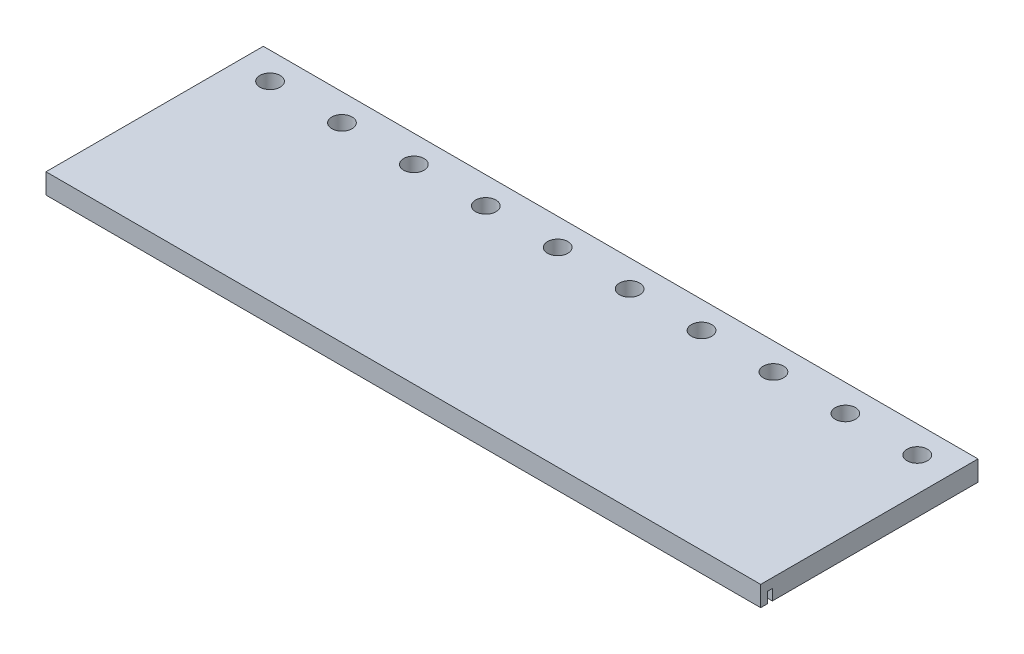
from build123d import *

# Parameters (mm, degrees)
SKETCH1_W               = 673.1
SKETCH1_H               = 204.6732
BOSS_EXTRUDE1_DEPTH     = 9.525
SKETCH2_R               = 9.584587104
CUT_EXTRUDE1_DEPTH      = 1
CUT_EXTRUDE1_DEPTH_BACK = 20.05
SKETCH4_W               = 673.1
SKETCH4_H               = 4.699
CUT_EXTRUDE2_DEPTH      = 10.16
CUT_EXTRUDE5_DEPTH      = 7.9375


with BuildPart() as part:
    # Sketch1 → Boss-Extrude1 (new body, symmetric)
    with BuildSketch(Plane(origin=(0, 0, 0), x_dir=(1, 0, 0), z_dir=(0, 1, 0))):
        Rectangle(SKETCH1_W, SKETCH1_H)
    extrude(amount=BOSS_EXTRUDE1_DEPTH, both=True)

    # Sketch2 → Cut-Extrude1 (cut, two sides)
    with BuildSketch(Plane(origin=(0, 9.525, 0), x_dir=(1, 0, 0), z_dir=(0, 1, 0))) as cut_extrude1_sk:
        with Locations((-304.8, 76.930371018)):
            Circle(SKETCH2_R)
        with Locations((-237.0709, 76.930371018)):
            Circle(SKETCH2_R)
        with Locations((-169.3418, 76.930371018)):
            Circle(SKETCH2_R)
        with Locations((-101.6127, 76.930371018)):
            Circle(SKETCH2_R)
        with Locations((-33.8836, 76.930371018)):
            Circle(SKETCH2_R)
        with Locations((33.8455, 76.930371018)):
            Circle(SKETCH2_R)
        with Locations((101.5746, 76.930371018)):
            Circle(SKETCH2_R)
        with Locations((169.3037, 76.930371018)):
            Circle(SKETCH2_R)
        with Locations((237.0328, 76.930371018)):
            Circle(SKETCH2_R)
        with Locations((304.7619, 76.930371018)):
            Circle(SKETCH2_R)
    extrude(amount=CUT_EXTRUDE1_DEPTH, mode=Mode.SUBTRACT)
    extrude(cut_extrude1_sk.sketch, amount=-CUT_EXTRUDE1_DEPTH_BACK, mode=Mode.SUBTRACT)

    # Sketch4 → Cut-Extrude2 (cut)
    with BuildSketch(Plane.XZ.offset(9.525)):
        with Locations((0, 93.6860458)):
            Rectangle(SKETCH4_W, SKETCH4_H)
    extrude(amount=-CUT_EXTRUDE2_DEPTH, mode=Mode.SUBTRACT)

    # Sketch7 → Cut-Extrude5 (cut)
    with BuildSketch(Plane.XZ.offset(9.525)):
        with BuildLine():
            Line((-323.05625, -26.291096465), (323.05625, -26.291096465))
            ThreePointArc((323.05625, -26.291096465), (331.05725, -34.292096465), (323.05625, -42.293096465))
            Line((323.05625, -42.293096465), (-323.05625, -42.293096465))
            ThreePointArc((-323.05625, -42.293096465), (-331.05725, -34.292096465), (-323.05625, -26.291096465))
        make_face()
    extrude(amount=-CUT_EXTRUDE5_DEPTH, mode=Mode.SUBTRACT)


solid = part.part
